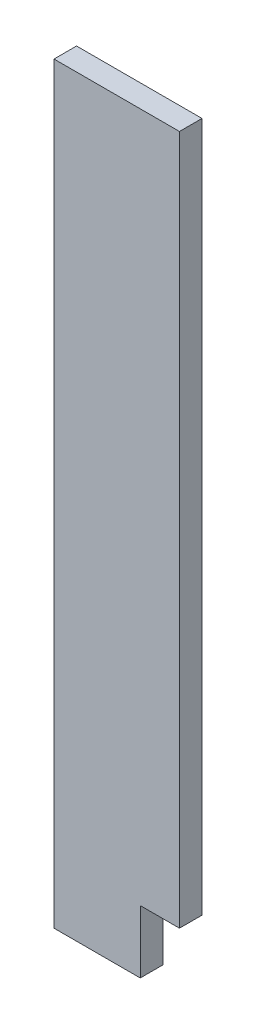
from build123d import *

# Parameters (mm, degrees)
SKETCH1_W           = 101.6
SKETCH1_H           = 609.6
BOSS_EXTRUDE1_DEPTH = 18.25625
SKETCH2_W           = 31.75
SKETCH2_H           = 50.8
CUT_EXTRUDE1_DEPTH  = 19.25625


with BuildPart() as part:
    # Sketch1 → Boss-Extrude1 (new body)
    with BuildSketch(Plane.XY):
        with Locations((-1.581946292, -194.081099888)):
            Rectangle(SKETCH1_W, SKETCH1_H)
    extrude(amount=BOSS_EXTRUDE1_DEPTH)

    # Sketch2 → Cut-Extrude1 (cut, through all)
    with BuildSketch(Plane.XY.offset(18.25625)):
        with Locations((33.343053708, -473.481099888)):
            Rectangle(SKETCH2_W, SKETCH2_H)
    extrude(amount=-CUT_EXTRUDE1_DEPTH, mode=Mode.SUBTRACT)


solid = part.part
